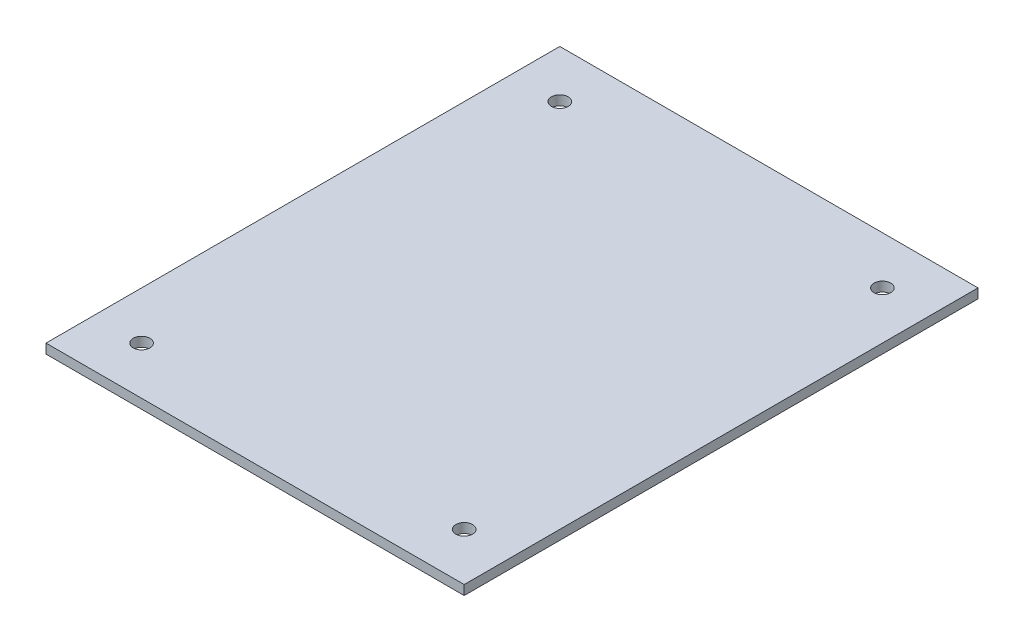
from build123d import *

# Parameters (mm, degrees)
SKETCH1_W           = 175
SKETCH1_H           = 215
SKETCH1_R           = 3.5
BOSS_EXTRUDE1_DEPTH = 4


with BuildPart() as part:
    # Sketch1 → Boss-Extrude1 (new body)
    with BuildSketch(Plane(origin=(0, 0, 0), x_dir=(1, 0, 0), z_dir=(0, 1, 0))):
        with Locations((87.5, 97.5)):
            Rectangle(SKETCH1_W, SKETCH1_H)
        with Locations((20, 10)):
            Circle(SKETCH1_R, mode=Mode.SUBTRACT)
        with Locations((155, 10)):
            Circle(SKETCH1_R, mode=Mode.SUBTRACT)
        with Locations((20, 185)):
            Circle(SKETCH1_R, mode=Mode.SUBTRACT)
        with Locations((155, 185)):
            Circle(SKETCH1_R, mode=Mode.SUBTRACT)
    extrude(amount=BOSS_EXTRUDE1_DEPTH)


solid = part.part
